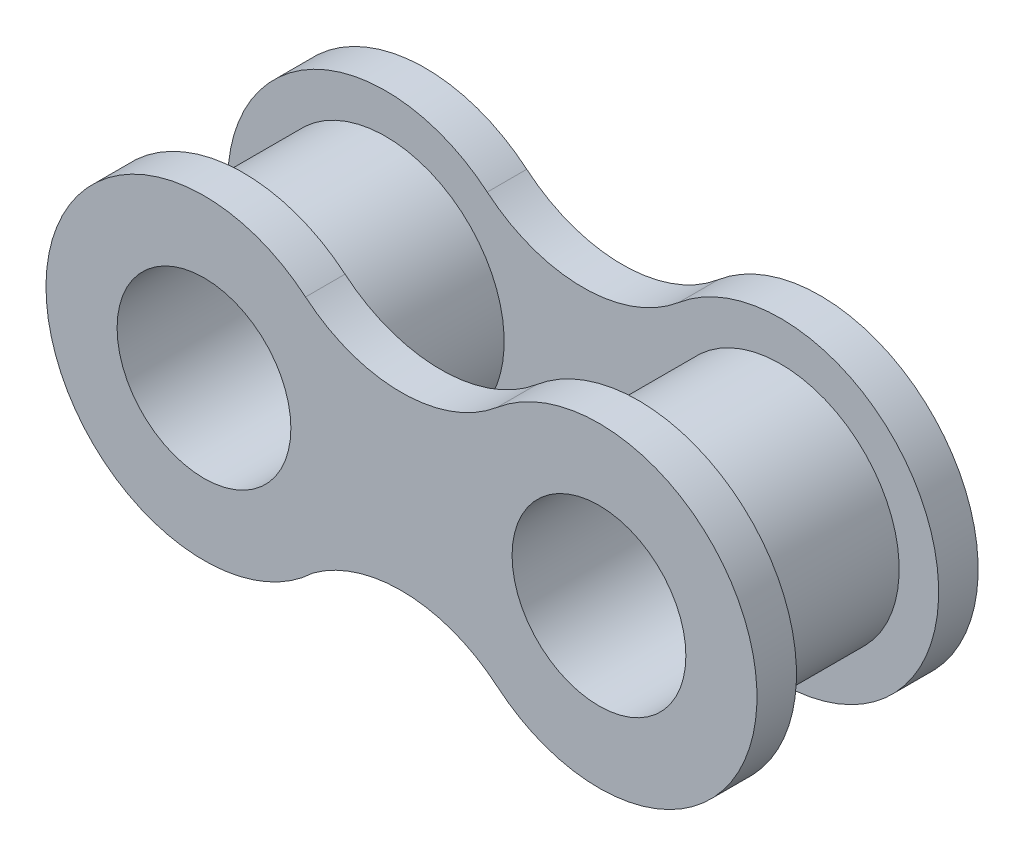
from build123d import *

# Parameters (mm, degrees)
BOSS_EXTRUDE1_DEPTH = 1.27
SKETCH2_R           = 3.81
BOSS_EXTRUDE2_DEPTH = 4.572
SKETCH5_R           = 2.794
CUT_EXTRUDE1_DEPTH  = 24.638


with BuildPart() as part:
    # Sketch1 → Boss-Extrude1 (new body)
    with BuildSketch(Plane.XY):
        with BuildLine():
            ThreePointArc((-26.191844276, -6.037143701), (-34.535215397, -10.092878556), (-25.946396087, -13.599017422))
            ThreePointArc((-25.946396087, -13.599017422), (-22.954821865, -12.674647532), (-20.032282841, -13.798365326))
            ThreePointArc((-20.032282841, -13.798365326), (-11.677896645, -9.914450414), (-20.032282841, -6.030535502))
            ThreePointArc((-20.032282841, -6.030535502), (-23.110858628, -7.156966052), (-26.191844276, -6.037143701))
        make_face()
    boss_extrude1 = extrude(amount=BOSS_EXTRUDE1_DEPTH)

    # Sketch2 → Boss-Extrude2 (add)
    with BuildSketch(Plane.XY.offset(1.27)):
        with Locations((-16.757896645, -9.914450414)):
            Circle(SKETCH2_R)
        with Locations((-29.457889337, -9.928075423)):
            Circle(SKETCH2_R)
    extrude(amount=BOSS_EXTRUDE2_DEPTH)

    # Mirror1: Boss-Extrude1 across plane
    add(boss_extrude1.mirror(Plane.XY.offset(3.556)))

    # Sketch5 → Cut-Extrude1 (cut)
    with BuildSketch(Plane.XY.offset(7.112)):
        with Locations((-29.457889337, -9.928075423)):
            Circle(SKETCH5_R)
        with Locations((-16.757896645, -9.914450414)):
            Circle(SKETCH5_R)
    extrude(amount=-CUT_EXTRUDE1_DEPTH, mode=Mode.SUBTRACT)


solid = part.part
